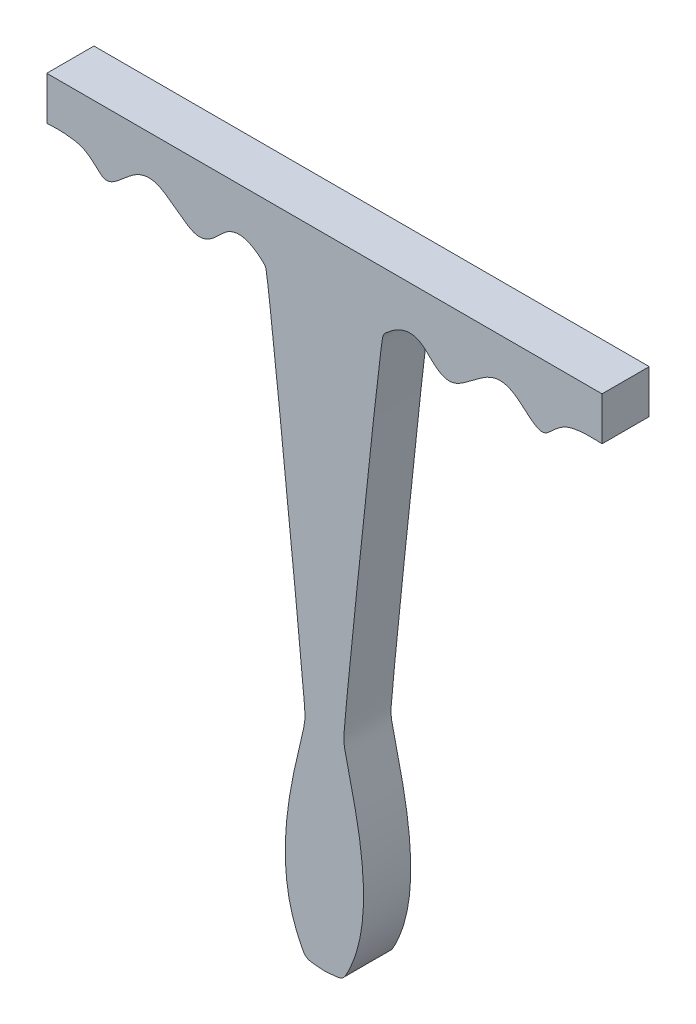
from build123d import *

# Parameters (mm, degrees)
BOSS_EXTRU_1_DEPTH = 8.5


with BuildPart() as part:
    # Esquisse1 → Boss.-Extru.1 (new body)
    with BuildSketch(Plane.XY):
        with BuildLine():
            Line((50, 24.202544964), (-50, 24.202544964))
            Line((-50, 24.202544964), (-50, 16.402544964))
            add(Edge.make_bspline(
                [(-50, 16.402544964), (-49.842140884, 16.386056111), (-42.403789104, 17.135775584), (-39.61868628, 10.786090771), (-33.934881415, 17.499050341), (-30.556444558, 17.285731582), (-26.896256798, 14.952205988), (-21.776794073, 10.249396089), (-16.686100319, 18.792396525), (-10.72825382, 14.080305631), (-10.095402885, 12.831804755), (-3.566973077, -49.809126391), (-3.328084029, -55.525769926), (-9.99556685, -75.874202551), (-3.496441737, -90.647819477), (-2.932310471, -90.596981582), (0, -90.797455036)],
                knots=[0, 0, 0, 0, 0.017426932, 0.034313336, 0.051765028, 0.072769477, 0.077742935, 0.101499608, 0.145976931, 0.215723624, 0.261466106, 0.565408908, 0.636790675, 0.903902006, 0.94356183, 1, 1, 1, 1], degree=3))
            add(Edge.make_bspline(
                [(50, 16.402544964), (49.842140884, 16.386056111), (42.403789104, 17.135775584), (39.61868628, 10.786090771), (33.934881415, 17.499050341), (30.556444558, 17.285731582), (26.896256798, 14.952205988), (21.776794073, 10.249396089), (16.686100319, 18.792396525), (10.72825382, 14.080305631), (10.095402885, 12.831804755), (3.566973077, -49.809126391), (3.328084029, -55.525769926), (9.99556685, -75.874202551), (3.496441737, -90.647819477), (2.932310471, -90.596981582), (0, -90.797455036)],
                knots=[0, 0, 0, 0, 0.017426932, 0.034313336, 0.051765028, 0.072769477, 0.077742935, 0.101499608, 0.145976931, 0.215723624, 0.261466106, 0.565408908, 0.636790675, 0.903902006, 0.94356183, 1, 1, 1, 1], degree=3))
            Line((50, 16.402544964), (50, 24.202544964))
        make_face()
    extrude(amount=BOSS_EXTRU_1_DEPTH)


solid = part.part
